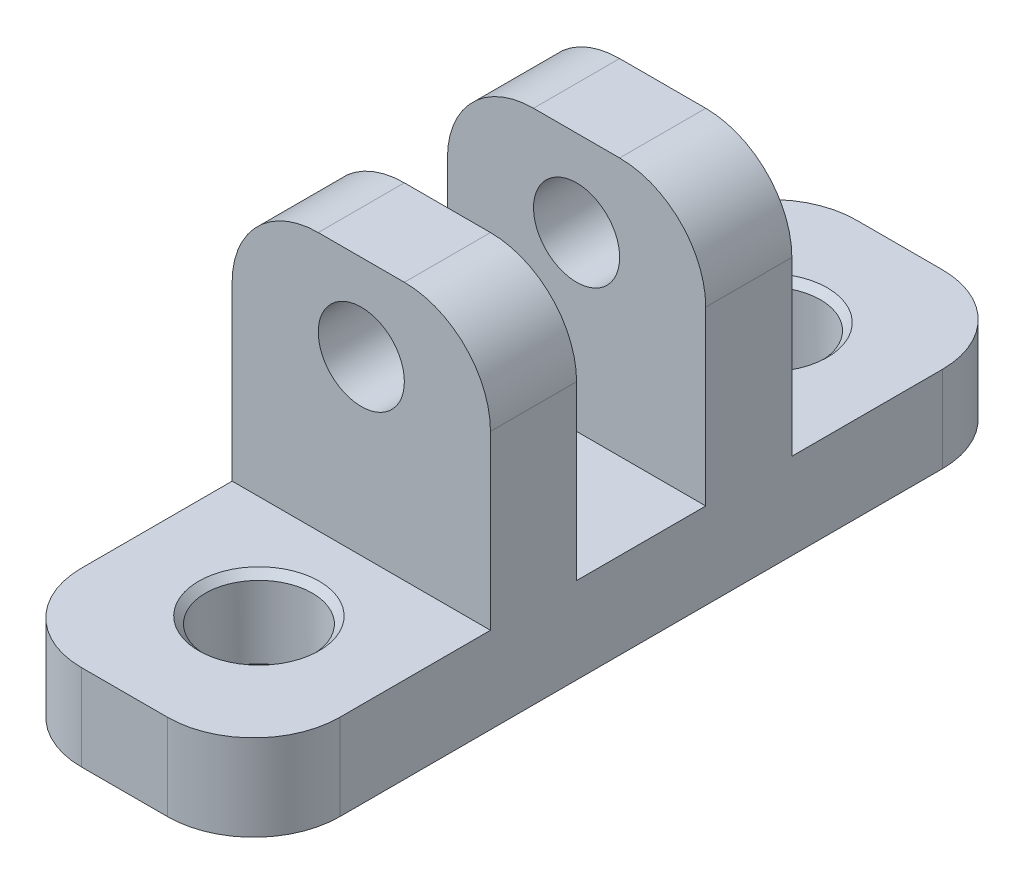
from build123d import *

# Parameters (mm, degrees)
SKETCH1_W           = 19.05
SKETCH1_H           = 57.15
BOSS_EXTRUDE1_DEPTH = 25.4
SKETCH2_W           = 17.4625
SKETCH2_H           = 19.05
SKETCH2_W_2         = 9.525
CUT_EXTRUDE1_DEPTH  = 20.05
SKETCH9_R           = 3.175
CUT_EXTRUDE3_DEPTH  = 40.6875
FILLET1_R           = 6.35
HOLE1_D             = 7.874
CHAMFER1_SIZE       = 0.508


with BuildPart() as part:
    # Sketch1 → Boss-Extrude1 (new body)
    with BuildSketch(Plane(origin=(0, 0, 0), x_dir=(1, 0, 0), z_dir=(0, 1, 0))):
        with Locations((69.85, 0)):
            Rectangle(SKETCH1_W, SKETCH1_H)
    extrude(amount=BOSS_EXTRUDE1_DEPTH)

    # Sketch2 → Cut-Extrude1 (cut, through all)
    with BuildSketch(Plane(origin=(79.375, 0, 0), x_dir=(0, 0, -1), z_dir=(1, 0, 0))):
        with Locations((-19.84375, 15.875)):
            Rectangle(SKETCH2_W, SKETCH2_H)
        with Locations((0, 15.875)):
            Rectangle(SKETCH2_W_2, SKETCH2_H)
        with Locations((19.84375, 15.875)):
            Rectangle(SKETCH2_W, SKETCH2_H)
    extrude(amount=-CUT_EXTRUDE1_DEPTH, mode=Mode.SUBTRACT)

    # Sketch9 → Cut-Extrude3 (cut, through all)
    with BuildSketch(Plane.XY.offset(11.1125)):
        with Locations((69.85, 19.05)):
            Circle(SKETCH9_R)
    extrude(amount=-CUT_EXTRUDE3_DEPTH, mode=Mode.SUBTRACT)

    # Fillet1
    fillet1_edges = [part.edges().sort_by_distance(p)[0] for p in [
        (79.375, 25.4, 7.9375),
        (79.375, 3.175, 28.575),
        (60.325, 3.175, 28.575),
        (79.375, 25.4, -7.9375),
        (60.325, 25.4, -7.9375),
        (60.325, 25.4, 7.9375),
        (60.325, 3.175, -28.575),
        (79.375, 3.175, -28.575),
    ]]
    fillet(fillet1_edges, radius=FILLET1_R)

    # Hole1 (through all)
    with Locations(Plane(origin=(0, 6.35, 0), x_dir=(1, 0, 0), z_dir=(0, 1, 0))):
        with Locations((69.923370565, 18.735910675), (69.923370565, -18.735910675)):
            Hole(HOLE1_D / 2)

    # Chamfer1
    chamfer1_edges = [part.edges().sort_by_distance(p)[0] for p in [
        (73.860370565, 6.35, 18.735910675),
        (73.860370565, 0, 18.735910675),
        (73.860370565, 6.35, -18.735910675),
        (73.860370565, 0, -18.735910675),
    ]]
    chamfer(chamfer1_edges, length=CHAMFER1_SIZE)


solid = part.part
